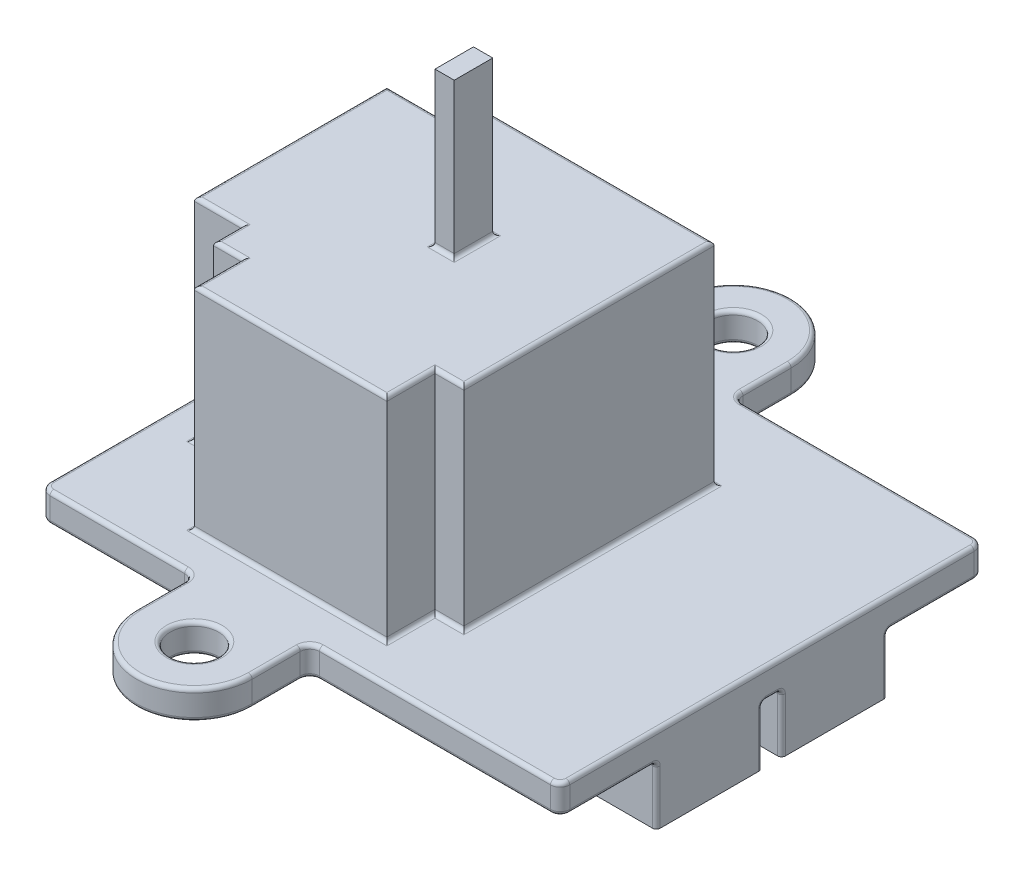
from build123d import *

# Parameters (mm, degrees)
SKETCH_1_R         = 1.25
PCB_DEPTH          = 1.5
SKETCH_6_W         = 4
SKETCH_6_H         = 5.5
EXTRUDE_2_DEPTH    = 3
SKETCH_3_W         = 13
SKETCH_3_H         = 13
EXTRUDE_2139_DEPTH = 11
SKETCH_7_W         = 10
SKETCH_7_H         = 11
EXTRUDE_3_DEPTH    = 2.5
SKETCH_8_W         = 10
SKETCH_8_H         = 11
EXTRUDE_4_DEPTH    = 2.5
SKETCH_9_W         = 1
SKETCH_9_H         = 2
EXTRUDE_5_DEPTH    = 8
FILLET_1_R         = 0.5
FILLET_2_R         = 0.2


with BuildPart() as part:
    # 草图1 → 凸台-拉伸-PCB板 (new body)
    with BuildSketch(Plane(origin=(0, 0, 0), x_dir=(1, 0, 0), z_dir=(0, 1, 0))):
        with BuildLine():
            ThreePointArc((-3, -14), (0, -17), (3, -14))
            Line((3, -14), (3, -11))
            Line((3, -11), (16, -11))
            Line((16, -11), (16, 11))
            Line((16, 11), (3, 11))
            Line((3, 11), (3, 14))
            ThreePointArc((3, 14), (0, 17), (-3, 14))
            Line((-3, 14), (-3, 11))
            Line((-3, 11), (-11, 11))
            Line((-11, 11), (-11, -11))
            Line((-11, -11), (-3, -11))
            Line((-3, -11), (-3, -14))
        make_face()
        with Locations((0, -14)):
            Circle(SKETCH_1_R, mode=Mode.SUBTRACT)
        with Locations((0, 14)):
            Circle(SKETCH_1_R, mode=Mode.SUBTRACT)
    extrude(amount=PCB_DEPTH)

    # 草图6 → 凸台-拉伸2 (add)
    with BuildSketch(Plane.XZ):
        with Locations((14, 3.25)):
            Rectangle(SKETCH_6_W, SKETCH_6_H)
        with Locations((14, -3.25)):
            Rectangle(SKETCH_6_W, SKETCH_6_H)
    extrude(amount=EXTRUDE_2_DEPTH)

    # 草图3 → Extrude 2139 (add)
    with BuildSketch(Plane(origin=(0, 1.5, 0), x_dir=(1, 0, 0), z_dir=(0, 1, 0))):
        Rectangle(SKETCH_3_W, SKETCH_3_H)
    extrude(amount=EXTRUDE_2139_DEPTH)

    # 草图7 → 凸台-拉伸3 (add)
    with BuildSketch(Plane.XY.offset(6.5)):
        with Locations((0, 7)):
            Rectangle(SKETCH_7_W, SKETCH_7_H)
    extrude(amount=EXTRUDE_3_DEPTH)

    # 草图8 → 凸台-拉伸4 (add)
    with BuildSketch(Plane.ZY.offset(6.5)):
        with Locations((0, 7)):
            Rectangle(SKETCH_8_W, SKETCH_8_H)
    extrude(amount=EXTRUDE_4_DEPTH)

    # 草图9 → 凸台-拉伸5 (add)
    with BuildSketch(Plane(origin=(0, 12.5, 0), x_dir=(1, 0, 0), z_dir=(0, 1, 0))):
        Rectangle(SKETCH_9_W, SKETCH_9_H)
    extrude(amount=EXTRUDE_5_DEPTH)

    # 圆角1
    fillet_1_edges = [part.edges().sort_by_distance(p)[0] for p in [
        (-11, 0.75, -11),
        (-3, 0.75, 11),
        (-11, 0.75, 11),
        (3, 0.75, 11),
        (16, 0.75, -11),
        (16, 0.75, 11),
        (-3, 0.75, -11),
        (3, 0.75, -11),
    ]]
    fillet(fillet_1_edges, radius=FILLET_1_R)

    # 圆角2
    fillet_2_edges = [part.edges().sort_by_distance(p)[0] for p in [
        (16, -1.5, 6),
        (16, -1.5, 0.5),
        (16, -1.5, -0.5),
        (16, -1.5, -6),
        (5.75, 12.5, 6.5),
        (5, 12.5, 7.75),
        (0, 12.5, 9),
        (-5, 12.5, 7.75),
        (-5.75, 12.5, 6.5),
        (-6.5, 12.5, 5.75),
        (-7.75, 12.5, 5),
        (-9, 12.5, 0),
        (-7.75, 12.5, -5),
        (-6.5, 12.5, -5.75),
        (0, 12.5, -6.5),
        (6.5, 12.5, 0),
        (0, 12.5, -1),
        (-0.5, 12.5, 0),
        (0, 12.5, 1),
        (0.5, 12.5, 0),
        (-5.75, 1.5, 6.5),
        (-5, 1.5, 7.75),
        (0, 1.5, 9),
        (5, 1.5, 7.75),
        (5.75, 1.5, 6.5),
        (6.5, 1.5, 0),
        (0, 1.5, -6.5),
        (-6.5, 1.5, -5.75),
        (-7.75, 1.5, -5),
        (-9, 1.5, 0),
        (-7.75, 1.5, 5),
        (-6.5, 1.5, 5.75),
        (-1.25, 1.5, 14),
        (-1.25, 1.5, -14),
        (-3.146446609, 1.5, -11.146446609),
        (-3, 1.5, -12.75),
        (0, 1.5, -17),
        (3, 1.5, -12.75),
        (3.146446609, 1.5, -11.146446609),
        (9.5, 1.5, -11),
        (15.853553391, 1.5, -10.853553391),
        (16, 1.5, 0),
        (15.853553391, 1.5, 10.853553391),
        (9.5, 1.5, 11),
        (3.146446609, 1.5, 11.146446609),
        (3, 1.5, 12.75),
        (0, 1.5, 17),
        (-3, 1.5, 12.75),
        (-3.146446609, 1.5, 11.146446609),
        (-7, 1.5, 11),
        (-10.853553391, 1.5, 10.853553391),
        (-11, 1.5, 0),
        (-10.853553391, 1.5, -10.853553391),
        (-7, 1.5, -11),
        (-10.853553391, 0, 10.853553391),
        (-7, 0, 11),
        (-3.146446609, 0, 11.146446609),
        (-3, 0, 12.75),
        (0, 0, 17),
        (3, 0, 12.75),
        (3.146446609, 0, 11.146446609),
        (9.5, 0, 11),
        (15.853553391, 0, 10.853553391),
        (16, 0, 8.25),
        (14, 0, 6),
        (12, 0, 3.25),
        (14, 0, 0.5),
        (16, 0, 0),
        (14, 0, -0.5),
        (12, 0, -3.25),
        (14, 0, -6),
        (16, 0, -8.25),
        (15.853553391, 0, -10.853553391),
        (9.5, 0, -11),
        (3.146446609, 0, -11.146446609),
        (3, 0, -12.75),
        (0, 0, -17),
        (-3, 0, -12.75),
        (-3.146446609, 0, -11.146446609),
        (-7, 0, -11),
        (-10.853553391, 0, -10.853553391),
        (-11, 0, 0),
        (-1.25, 0, 14),
        (-1.25, 0, -14),
    ]]
    fillet(fillet_2_edges, radius=FILLET_2_R)


solid = part.part
